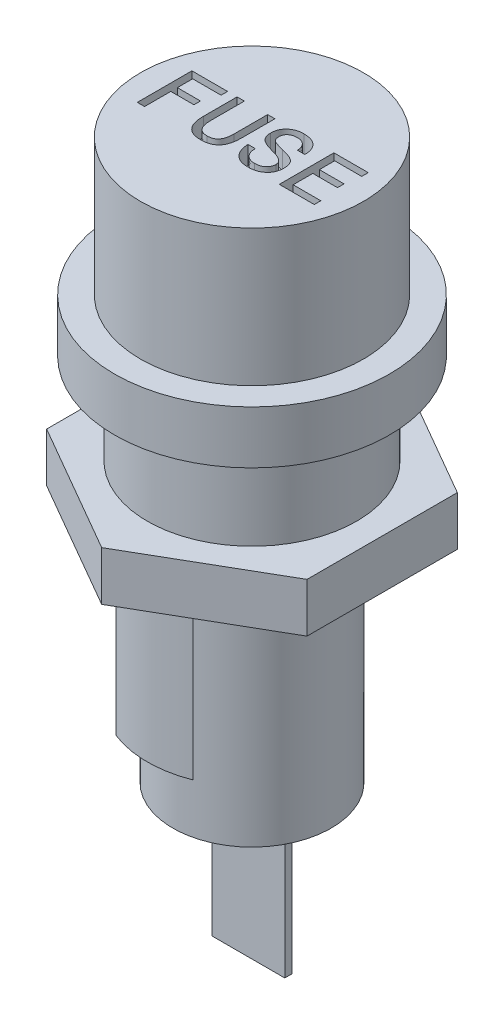
from build123d import *
from build123d.topology import SkipClean

# Parameters (mm, degrees)
SKETCH1_R           = 5.75
BOSS_EXTRUDE1_DEPTH = 7.7
SKETCH2_R           = 4.35
BOSS_EXTRUDE2_DEPTH = 12.6
SKETCH3_R           = 7.55
BOSS_EXTRUDE3_DEPTH = 2.9
SKETCH4_R           = 6.125
BOSS_EXTRUDE4_DEPTH = 7.5
CUT_EXTRUDE1_DEPTH  = 1
SKETCH6_R           = 5.75
BOSS_EXTRUDE5_DEPTH = 2.7
SKETCH7_W           = 4
SKETCH7_H           = 0.4
BOSS_EXTRUDE6_DEPTH = 8.2
BOSS_EXTRUDE7_DEPTH = 8.75


with BuildPart() as part:
    # Sketch1 → Boss-Extrude1 (new body)
    with BuildSketch(Plane(origin=(0, 0, 0), x_dir=(1, 0, 0), z_dir=(0, 1, 0))):
        with Locations(Location((0, 0, 0), (0, 0, 90))):
            Circle(SKETCH1_R)
    extrude(amount=BOSS_EXTRUDE1_DEPTH)

    # Sketch2 → Boss-Extrude2 (add)
    with BuildSketch(Plane.XZ):
        with Locations(Location((0, 0, 0), (0, 0, 270))):
            Circle(SKETCH2_R)
    extrude(amount=BOSS_EXTRUDE2_DEPTH)

    # Sketch3 → Boss-Extrude3 (add)
    with BuildSketch(Plane(origin=(0, 7.7, 0), x_dir=(1, 0, 0), z_dir=(0, 1, 0))):
        with Locations(Location((0, 0, 0), (0, 0, 270))):
            Circle(SKETCH3_R)
    extrude(amount=BOSS_EXTRUDE3_DEPTH)

    # Sketch4 → Boss-Extrude4 (add)
    with BuildSketch(Plane(origin=(0, 10.6, 0), x_dir=(1, 0, 0), z_dir=(0, 1, 0))):
        with Locations(Location((0, 0, 0), (0, 0, 270))):
            Circle(SKETCH4_R)
    extrude(amount=BOSS_EXTRUDE4_DEPTH)

    # Sketch5 → Cut-Extrude1 (cut)
    with BuildSketch(Plane(origin=(0, 18.1, 0), x_dir=(1, 0, 0), z_dir=(0, 1, 0))):
        Polygon((-4.8, -1.5), (-4.8, 1.5), (-2.84, 1.5), (-2.84, 1.14), (-4.4, 1.14), (-4.4, 0.3), (-3.130625, 0.3), (-3.130625, -0.06), (-4.4, -0.06), (-4.4, -1.5), align=None)
        with BuildLine():
            Line((-2.32, -0.33125), (-2.32, 1.5))
            Line((-2.32, 1.5), (-1.92, 1.5))
            Line((-1.92, 1.5), (-1.92, -0.35375))
            add(Edge.make_bspline(
                [(-1.92, -0.35375), (-1.91957852, -0.387726785), (-1.918762901, -0.453476463), (-1.910866301, -0.548573052), (-1.899744453, -0.637062747), (-1.881880785, -0.71839235), (-1.860464505, -0.793523123), (-1.832979314, -0.861476338), (-1.800930555, -0.92295122), (-1.764095385, -0.977731229), (-1.721691307, -1.025854707), (-1.67400333, -1.067655775), (-1.620180464, -1.101621659), (-1.562370686, -1.131226384), (-1.498399234, -1.152562829), (-1.429668192, -1.169046548), (-1.355457645, -1.178280983), (-1.304399114, -1.179415956), (-1.278125, -1.18)],
                knots=[0, 0, 0, 0, 1.360073625, 2.631926526, 3.818708106, 4.927970627, 5.962652761, 6.943160364, 7.85730642, 8.734156257, 9.579286345, 10.418923555, 11.263435933, 12.121435206, 13.0130786, 13.955926283, 14.94814396, 16, 16, 16, 16], degree=3))
            add(Edge.make_bspline(
                [(-1.278125, -1.18), (-1.252043362, -1.179513323), (-1.201341787, -1.178567245), (-1.128188009, -1.168029938), (-1.059921425, -1.15288112), (-0.996843528, -1.130334683), (-0.939267187, -1.100558785), (-0.885926316, -1.065741701), (-0.838904075, -1.023127692), (-0.79644759, -0.97463019), (-0.759847458, -0.918994238), (-0.726960309, -0.857729921), (-0.70047369, -0.789320357), (-0.677608931, -0.71488057), (-0.661519578, -0.633535627), (-0.648774342, -0.546166175), (-0.641334862, -0.452211542), (-0.640454907, -0.38730463), (-0.64, -0.35375)],
                knots=[0, 0, 0, 0, 1.048272959, 2.037797277, 2.966711225, 3.857304793, 4.722990938, 5.568945272, 6.411656318, 7.266938429, 8.154728712, 9.084360479, 10.058437057, 11.100226172, 12.212805666, 13.389548815, 14.650486967, 16, 16, 16, 16], degree=3))
            Line((-0.64, -0.35375), (-0.64, 1.5))
            Line((-0.64, 1.5), (-0.24, 1.5))
            Line((-0.24, 1.5), (-0.24, -0.33125))
            add(Edge.make_bspline(
                [(-0.24, -0.33125), (-0.240614031, -0.381067698), (-0.241800323, -0.477314114), (-0.253875271, -0.616783179), (-0.273440662, -0.746354376), (-0.301420053, -0.865932199), (-0.336995828, -0.975670549), (-0.380385202, -1.075474024), (-0.432766046, -1.165157975), (-0.492858034, -1.24520681), (-0.561752616, -1.315434362), (-0.639223435, -1.375750645), (-0.72523725, -1.426619394), (-0.819597865, -1.469008613), (-0.923335348, -1.500208112), (-1.035030116, -1.523115073), (-1.15522306, -1.538079112), (-1.238286427, -1.539345154), (-1.28125, -1.54)],
                knots=[0, 0, 0, 0, 1.303190653, 2.517728355, 3.659480693, 4.729120228, 5.727182494, 6.674160857, 7.570724162, 8.438523653, 9.286529549, 10.13703702, 10.99989194, 11.895394105, 12.83678664, 13.827798119, 14.876453491, 16, 16, 16, 16], degree=3))
            add(Edge.make_bspline(
                [(-1.28125, -1.54), (-1.32379699, -1.539338477), (-1.406236888, -1.538056697), (-1.525597078, -1.52311115), (-1.63668108, -1.500231346), (-1.739944426, -1.468880914), (-1.834141382, -1.426630968), (-1.920150882, -1.375747723), (-1.997621609, -1.315434837), (-2.066520769, -1.245207806), (-2.126593933, -1.165153318), (-2.17904934, -1.075492685), (-2.222163786, -0.975534729), (-2.258960866, -0.866159973), (-2.285693049, -0.746236013), (-2.305382842, -0.616769217), (-2.318404809, -0.47734634), (-2.319456, -0.381072469), (-2.32, -0.33125)],
                knots=[0, 0, 0, 0, 1.114454924, 2.159390091, 3.14666343, 4.084367365, 4.981321447, 5.845575353, 6.69746179, 7.546842595, 8.416049089, 9.314066032, 10.262579773, 11.263973365, 12.33410829, 13.477711802, 14.694696426, 16, 16, 16, 16], degree=3))
        make_face()
        with BuildLine():
            add(Edge.make_bspline(
                [(0.64, -0.46), (0.640619677, -0.486900569), (0.641833577, -0.539596762), (0.650721323, -0.616299788), (0.664811974, -0.689012667), (0.685824402, -0.756980136), (0.710908996, -0.821622629), (0.744043798, -0.880782039), (0.781443728, -0.936567171), (0.825428211, -0.986987436), (0.873912891, -1.032571589), (0.92674759, -1.072156471), (0.983580796, -1.105898314), (1.044951062, -1.132263684), (1.109942567, -1.153793697), (1.178731379, -1.169550538), (1.251865529, -1.17811195), (1.3018538, -1.179359798), (1.3275, -1.18)],
                knots=[0, 0, 0, 0, 1.147296579, 2.247467727, 3.289724006, 4.301839324, 5.278814069, 6.241291386, 7.187840425, 8.139258211, 9.088681583, 10.02182696, 10.950050293, 11.901135967, 12.865089225, 13.867599669, 14.905984056, 16, 16, 16, 16], degree=3))
            add(Edge.make_bspline(
                [(1.3275, -1.18), (1.350854836, -1.179514568), (1.396417895, -1.178567536), (1.462999512, -1.17133984), (1.526204987, -1.160898014), (1.585232975, -1.143205306), (1.641379438, -1.122986772), (1.693725205, -1.097376103), (1.742540273, -1.067024143), (1.787222617, -1.032107563), (1.827982599, -0.993662053), (1.862923825, -0.951372213), (1.893637837, -0.90678274), (1.917791936, -0.858496649), (1.93678169, -0.807123255), (1.950397996, -0.7528718), (1.95879338, -0.695470858), (1.959591905, -0.656279307), (1.96, -0.63625)],
                knots=[0, 0, 0, 0, 1.19330924, 2.328032603, 3.420401274, 4.461760744, 5.472456819, 6.46772324, 7.433856963, 8.40508195, 9.361544657, 10.291320178, 11.203864745, 12.122908779, 13.042631051, 13.998145004, 14.976928276, 16, 16, 16, 16], degree=3))
            add(Edge.make_bspline(
                [(1.96, -0.63625), (1.959561344, -0.622457631), (1.958697224, -0.595287663), (1.950520656, -0.555330131), (1.939048947, -0.516530351), (1.921674962, -0.478961834), (1.899233501, -0.4429983), (1.871721811, -0.408483811), (1.840744387, -0.374174819), (1.803133978, -0.342899707), (1.762099015, -0.311004764), (1.714939602, -0.282182027), (1.663475312, -0.254154375), (1.60777072, -0.226161442), (1.546358758, -0.200920587), (1.480091034, -0.176873878), (1.409508997, -0.152601409), (1.360287503, -0.138909307), (1.335, -0.131875)],
                knots=[0, 0, 0, 0, 0.76766232, 1.512239123, 2.265097258, 3.018402857, 3.810946352, 4.621483474, 5.475899676, 6.381326497, 7.342641127, 8.370236005, 9.45618482, 10.608848279, 11.842182918, 13.153490056, 14.537607765, 16, 16, 16, 16], degree=3))
            add(Edge.make_bspline(
                [(1.335, -0.131875), (1.315439741, -0.126373152), (1.278658387, -0.11602741), (1.226545638, -0.102737963), (1.18177343, -0.089813112), (1.153973467, -0.082652338), (1.14125, -0.079375)],
                knots=[0, 0, 0, 0, 1.214619566, 2.283985805, 3.214615823, 4, 4, 4, 4], degree=3))
            add(Edge.make_bspline(
                [(1.14125, -0.079375), (1.101172595, -0.067754111), (1.0242037, -0.045436124), (0.91464817, -0.00926461), (0.815819905, 0.027835736), (0.727940374, 0.066820729), (0.650365193, 0.105921889), (0.582914409, 0.145404815), (0.526897073, 0.187043576), (0.479641898, 0.229362628), (0.441753939, 0.275718648), (0.40880377, 0.324761206), (0.381273832, 0.378284536), (0.358756116, 0.436108142), (0.341292965, 0.498292789), (0.329009124, 0.564605291), (0.321320976, 0.635027536), (0.320448392, 0.683312798), (0.32, 0.708125)],
                knots=[0, 0, 0, 0, 1.598378329, 3.069695164, 4.418491952, 5.640440353, 6.750436261, 7.745457553, 8.629723984, 9.420490962, 10.168459231, 10.916597783, 11.680448433, 12.468876216, 13.289950484, 14.150823048, 15.049769031, 16, 16, 16, 16], degree=3))
            add(Edge.make_bspline(
                [(0.32, 0.708125), (0.320918622, 0.740033274), (0.322714359, 0.802408052), (0.33445462, 0.893579775), (0.355225149, 0.979841812), (0.384244217, 1.061375481), (0.420254, 1.138925122), (0.465714585, 1.211088277), (0.519362764, 1.278373343), (0.580404317, 1.340701755), (0.64833162, 1.396795549), (0.721926822, 1.445441617), (0.799716996, 1.488110565), (0.883389112, 1.52154598), (0.971884852, 1.547914243), (1.065413377, 1.566463636), (1.163878227, 1.577972625), (1.231217563, 1.579314408), (1.265625, 1.58)],
                knots=[0, 0, 0, 0, 1.058438333, 2.069051262, 3.042891741, 3.995862672, 4.935637382, 5.873275313, 6.817637842, 7.785230169, 8.762081964, 9.733835998, 10.707848102, 11.69983601, 12.716550152, 13.766903584, 14.858986033, 16, 16, 16, 16], degree=3))
            add(Edge.make_bspline(
                [(1.265625, 1.58), (1.304824977, 1.579380829), (1.381124451, 1.578175666), (1.492063911, 1.565937799), (1.596182957, 1.546800221), (1.69365155, 1.520161249), (1.784317912, 1.484937225), (1.868259177, 1.441988342), (1.945156954, 1.390730153), (2.015515658, 1.332664486), (2.078072477, 1.267013107), (2.132187782, 1.194488218), (2.177993805, 1.115825705), (2.215895012, 1.030864974), (2.244321998, 0.939082112), (2.264813542, 0.841153408), (2.277545971, 0.736790908), (2.279166401, 0.665037258), (2.28, 0.628125)],
                knots=[0, 0, 0, 0, 1.189050784, 2.314387812, 3.381901389, 4.398742921, 5.375453501, 6.328243036, 7.253973412, 8.174248591, 9.090868934, 9.99864003, 10.913711382, 11.847607597, 12.815275128, 13.823255256, 14.880216359, 16, 16, 16, 16], degree=3))
            Line((2.28, 0.628125), (2.28, 0.62))
            Line((2.28, 0.62), (1.88, 0.62))
            add(Edge.make_bspline(
                [(1.88, 0.62), (1.877581564, 0.643576738), (1.872873453, 0.689474956), (1.861169451, 0.756006354), (1.844566224, 0.81810681), (1.825313185, 0.87651638), (1.799583907, 0.929849317), (1.77117502, 0.979630693), (1.7377835, 1.024690697), (1.700783615, 1.065587352), (1.65982707, 1.102176893), (1.615076865, 1.134067146), (1.566307098, 1.160180518), (1.514652908, 1.182650779), (1.458908453, 1.198930612), (1.399894284, 1.21192575), (1.337019988, 1.21842047), (1.293969944, 1.219464278), (1.271875, 1.22)],
                knots=[0, 0, 0, 0, 1.18740492, 2.31159073, 3.380113405, 4.406818849, 5.387488257, 6.341800448, 7.275098108, 8.191486909, 9.100892347, 10.021966466, 10.937581968, 11.868307267, 12.839204637, 13.842450165, 14.892662182, 16, 16, 16, 16], degree=3))
            add(Edge.make_bspline(
                [(1.271875, 1.22), (1.25143628, 1.219737311), (1.211498959, 1.219224016), (1.153322822, 1.212387745), (1.098012168, 1.20355257), (1.045895749, 1.189715841), (0.997144718, 1.171665044), (0.951653298, 1.149441787), (0.909064562, 1.123897503), (0.869794846, 1.094711847), (0.834529558, 1.062066113), (0.804028915, 1.026545554), (0.777912875, 0.988470666), (0.756561332, 0.947825196), (0.740426162, 0.904262565), (0.728281183, 0.858266251), (0.721584331, 0.809571448), (0.72053321, 0.776268721), (0.72, 0.759375)],
                knots=[0, 0, 0, 0, 1.211709875, 2.367684722, 3.47092749, 4.532112956, 5.560553205, 6.549935904, 7.531258325, 8.502647206, 9.447089874, 10.376042143, 11.274147444, 12.180716043, 13.091989756, 14.024224552, 14.997733772, 16, 16, 16, 16], degree=3))
            add(Edge.make_bspline(
                [(0.72, 0.759375), (0.720390196, 0.742488449), (0.721143486, 0.709888278), (0.726063426, 0.662604056), (0.734678795, 0.618827794), (0.747050455, 0.578491738), (0.763611776, 0.541992766), (0.782928111, 0.508400702), (0.806150125, 0.478457923), (0.833720375, 0.450443781), (0.869685818, 0.424938829), (0.915959405, 0.400425084), (0.973077898, 0.374717082), (1.042200451, 0.349550434), (1.122735345, 0.323535403), (1.214774298, 0.296542723), (1.318500798, 0.270024079), (1.3916366, 0.252790092), (1.43, 0.24375)],
                knots=[0, 0, 0, 0, 0.83249952, 1.607174044, 2.340363172, 3.029038395, 3.681856198, 4.312482357, 4.93494282, 5.54499305, 6.243478197, 7.098420068, 8.123539759, 9.329246456, 10.722625318, 12.295690788, 14.056903854, 16, 16, 16, 16], degree=3))
            add(Edge.make_bspline(
                [(1.43, 0.24375), (1.475506475, 0.232849221), (1.562956103, 0.211901233), (1.687164927, 0.176246935), (1.799369418, 0.139442522), (1.899596886, 0.101804133), (1.987608135, 0.06187124), (2.063391114, 0.020272361), (2.127509302, -0.022712269), (2.180042336, -0.068687196), (2.223655603, -0.117914474), (2.259918274, -0.171821789), (2.291435761, -0.229818671), (2.316431837, -0.293523635), (2.336509147, -0.361863131), (2.349685246, -0.435651673), (2.359045347, -0.513926162), (2.359675872, -0.567886271), (2.36, -0.595625)],
                knots=[0, 0, 0, 0, 1.6140307, 3.101676927, 4.456158051, 5.686748787, 6.79302041, 7.787009774, 8.666070904, 9.450301289, 10.18856619, 10.928089259, 11.686915271, 12.460937168, 13.284235741, 14.139804949, 15.043748306, 16, 16, 16, 16], degree=3))
            add(Edge.make_bspline(
                [(2.36, -0.595625), (2.359179239, -0.630870107), (2.357575434, -0.699740712), (2.344484933, -0.8003383), (2.321531653, -0.895164855), (2.291565639, -0.98509246), (2.25071568, -1.068798935), (2.202268187, -1.147562671), (2.143156269, -1.2195065), (2.077159765, -1.286421488), (2.003567664, -1.346787024), (1.922038141, -1.39751406), (1.835809348, -1.442763476), (1.742403507, -1.477856948), (1.643472889, -1.506559798), (1.537805828, -1.524937822), (1.426387522, -1.538413373), (1.349836207, -1.539462576), (1.310625, -1.54)],
                knots=[0, 0, 0, 0, 1.060692937, 2.072644153, 3.046090986, 3.994015708, 4.919586263, 5.843540917, 6.771000199, 7.715496235, 8.669417269, 9.627964773, 10.601169194, 11.595716953, 12.625923118, 13.697221865, 14.820468178, 16, 16, 16, 16], degree=3))
            add(Edge.make_bspline(
                [(1.310625, -1.54), (1.270587449, -1.539206125), (1.192578205, -1.537659337), (1.079025508, -1.524319325), (0.972107123, -1.502565076), (0.871919016, -1.472154818), (0.778304861, -1.432606366), (0.691925155, -1.383356284), (0.611325458, -1.326677731), (0.538564136, -1.260528268), (0.473392456, -1.186373793), (0.415578277, -1.104789787), (0.366030856, -1.015464157), (0.324916322, -0.918543949), (0.291029591, -0.81444823), (0.265731338, -0.702925896), (0.248053321, -0.584016375), (0.242736523, -0.50214084), (0.24, -0.46)],
                knots=[0, 0, 0, 0, 1.119608807, 2.181448015, 3.192888102, 4.168020096, 5.105366308, 6.029118744, 6.944321237, 7.856103651, 8.772696538, 9.700776737, 10.647710759, 11.624078254, 12.641326886, 13.705769369, 14.819173456, 16, 16, 16, 16], degree=3))
            Line((0.24, -0.46), (0.64, -0.46))
        make_face()
        Polygon((3, -1.5), (3, 1.5), (4.885625, 1.5), (4.885625, 1.14), (3.4, 1.14), (3.4, 0.3), (4.755625, 0.3), (4.755625, -0.06), (3.4, -0.06), (3.4, -1.14), (4.92, -1.14), (4.92, -1.5), align=None)
    extrude(amount=-CUT_EXTRUDE1_DEPTH, mode=Mode.SUBTRACT)

    # Sketch7 → Boss-Extrude6 (add)
    with BuildSketch(Plane.XZ.offset(12.6)):
        Rectangle(SKETCH7_W, SKETCH7_H)
    extrude(amount=BOSS_EXTRUDE6_DEPTH)



with BuildPart() as body_2:
    # Sketch6 → Boss-Extrude5 (new body)
    with BuildSketch(Plane.XZ):
        Polygon((-7.15, 4.128054425), (-7.15, -4.128054425), (0, -8.256108849), (7.15, -4.128054425), (7.15, 4.128054425), (0, 8.256108849), align=None)
        with Locations(Location((0, 0, 0), (0, 0, 270))):
            Circle(SKETCH6_R, mode=Mode.SUBTRACT)
    extrude(amount=-BOSS_EXTRUDE5_DEPTH)


with BuildPart() as part_1:
    with SkipClean():  # the faces are left unmerged after this step: merging them gives an invalid solid
        add(part.part)

        add(body_2.part)  # Boss-Extrude7 merges body 2
        # Sketch8 → Boss-Extrude7 (add)
        with BuildSketch(Plane.XZ):
            with BuildLine():
                Line((-2.107130751, 5.35), (2.107130751, 5.35))
                ThreePointArc((2.107130751, 5.35), (0, 5.75), (-2.107130751, 5.35))
            make_face()
        extrude(amount=BOSS_EXTRUDE7_DEPTH)


solid = part_1.part
